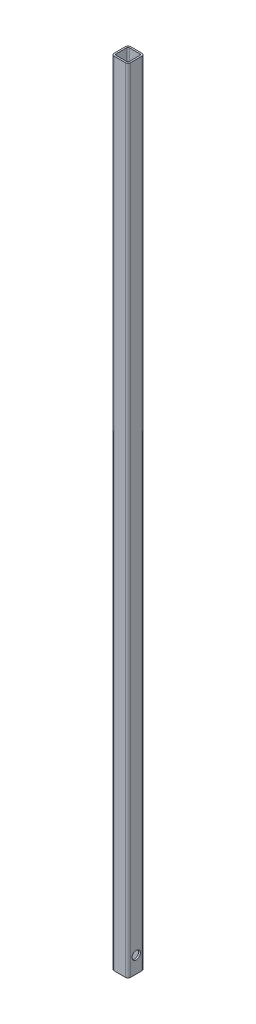
from build123d import *

# Parameters (mm, degrees)
BOSS_EXTRUDE1_DEPTH = 1219.2
SKETCH3_R           = 6.35
CUT_EXTRUDE2_DEPTH  = 26.4


with BuildPart() as part:
    # Sketch1 → Boss-Extrude1 (new body)
    with BuildSketch(Plane(origin=(0, 0, 0), x_dir=(1, 0, 0), z_dir=(0, 1, 0))):
        with BuildLine():
            Line((4, 0), (21.4, 0))
            ThreePointArc((21.4, 0), (24.228427125, 1.171572875), (25.4, 4))
            Line((25.4, 4), (25.4, 21.4))
            ThreePointArc((25.4, 21.4), (24.228427125, 24.228427125), (21.4, 25.4))
            Line((21.4, 25.4), (4, 25.4))
            ThreePointArc((4, 25.4), (1.171572875, 24.228427125), (0, 21.4))
            Line((0, 21.4), (0, 4))
            ThreePointArc((0, 4), (1.171572875, 1.171572875), (4, 0))
        make_face()
        with BuildLine():
            Line((20.86, 2.54), (4.54, 2.54))
            ThreePointArc((4.54, 2.54), (3.125786438, 3.125786438), (2.54, 4.54))
            Line((2.54, 4.54), (2.54, 20.86))
            ThreePointArc((2.54, 20.86), (3.125786438, 22.274213562), (4.54, 22.86))
            Line((4.54, 22.86), (20.86, 22.86))
            ThreePointArc((20.86, 22.86), (22.274213562, 22.274213562), (22.86, 20.86))
            Line((22.86, 20.86), (22.86, 4.54))
            ThreePointArc((22.86, 4.54), (22.274213562, 3.125786438), (20.86, 2.54))
        make_face(mode=Mode.SUBTRACT)
    extrude(amount=BOSS_EXTRUDE1_DEPTH)

    # Sketch3 → Cut-Extrude2 (cut, through all)
    with BuildSketch(Plane(origin=(25.4, 0, 0), x_dir=(0, 0, -1), z_dir=(1, 0, 0))):
        with Locations((12.7, 25.4)):
            Circle(SKETCH3_R)
    extrude(amount=-CUT_EXTRUDE2_DEPTH, mode=Mode.SUBTRACT)


solid = part.part
